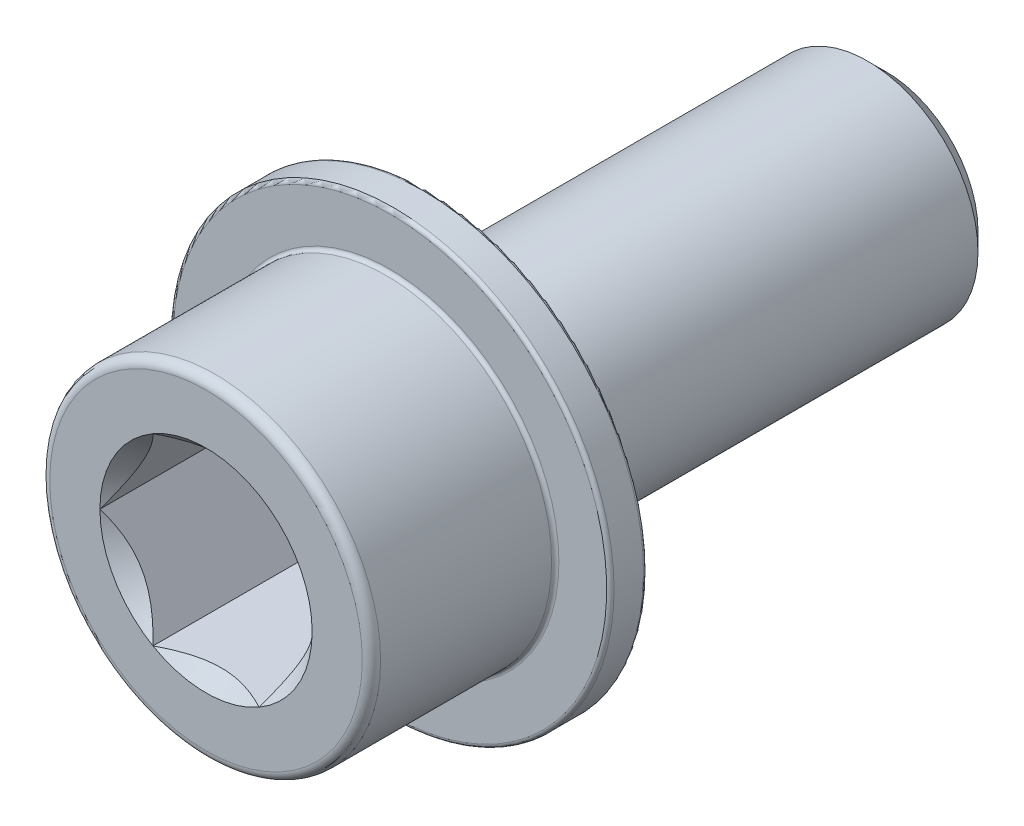
from build123d import *

# Parameters (mm, degrees)
SCHIZZO1_R                   = 6
ESTRUSIONE_ESTRUSIONE1_DEPTH = 25
SMUSSO1_SIZE                 = 1
SCHIZZO6_R                   = 9
ESTRUSIONE_ESTRUSIONE3_DEPTH = 12
TAGLIO_ESTRUSIONE3_DEPTH     = 8
SCHIZZO8_R                   = 5.773502692
TAGLIO_ESTRUSIONE4_DEPTH     = 1
TAGLIO_ESTRUSIONE4_TAPER     = 43
RACCORDO4_R                  = 0.5
SCHIZZO9_R                   = 12
SCHIZZO9_R_2                 = 9
ESTRUSIONE_ESTRUSIONE4_DEPTH = 2
RACCORDO5_R                  = 0.2


with BuildPart() as part:
    # Schizzo1 → Estrusione-Estrusione1 (new body)
    with BuildSketch(Plane.XY):
        Circle(SCHIZZO1_R)
    extrude(amount=ESTRUSIONE_ESTRUSIONE1_DEPTH)

    # Smusso1
    smusso1_edges = [part.edges().sort_by_distance(p)[0] for p in [
        (-6, 0, 0),
    ]]
    chamfer(smusso1_edges, length=SMUSSO1_SIZE)

    # Schizzo6 → Estrusione-Estrusione3 (add)
    with BuildSketch(Plane.XY.offset(25)):
        Circle(SCHIZZO6_R)
    extrude(amount=ESTRUSIONE_ESTRUSIONE3_DEPTH)

    # Schizzo7 → Taglio-Estrusione3 (cut)
    with BuildSketch(Plane.XY.offset(37)):
        Polygon((2.886751346, 5), (-2.886751346, 5), (-5.773502692, 0), (-2.886751346, -5), (2.886751346, -5), (5.773502692, 0), align=None)
    extrude(amount=-TAGLIO_ESTRUSIONE3_DEPTH, mode=Mode.SUBTRACT)

    # Schizzo8 → Taglio-Estrusione4 (cut)
    with BuildSketch(Plane.XY.offset(37)):
        Circle(SCHIZZO8_R)
    extrude(amount=-TAGLIO_ESTRUSIONE4_DEPTH, taper=TAGLIO_ESTRUSIONE4_TAPER, mode=Mode.SUBTRACT)

    # Raccordo4
    raccordo4_edges = [part.edges().sort_by_distance(p)[0] for p in [
        (-9, 0, 37),
    ]]
    fillet(raccordo4_edges, radius=RACCORDO4_R)

    # Schizzo9 → Estrusione-Estrusione4 (add)
    with BuildSketch(Plane(origin=(0, 0, 25), x_dir=(-1, 0, 0), z_dir=(0, 0, -1))):
        Circle(SCHIZZO9_R)
        Circle(SCHIZZO9_R_2, mode=Mode.SUBTRACT)
    extrude(amount=-ESTRUSIONE_ESTRUSIONE4_DEPTH)

    # Raccordo5
    raccordo5_edges = [part.edges().sort_by_distance(p)[0] for p in [
        (-9, 0, 27),
        (12, 0, 27),
        (12, 0, 25),
    ]]
    fillet(raccordo5_edges, radius=RACCORDO5_R)


solid = part.part
